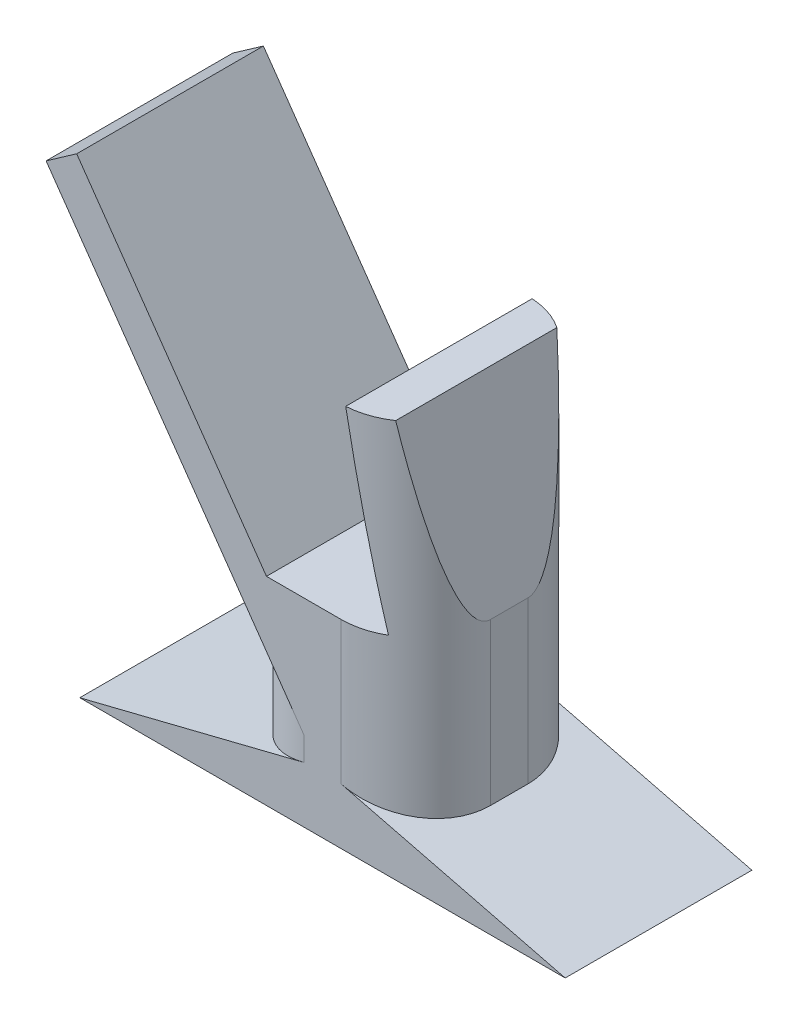
from build123d import *

# Parameters (mm, degrees)
BOSS_EXTRUDE1_DEPTH     = 12.7
FILLET2_R               = 5.08
SKETCH5_R               = 1.27
CUT_EXTRUDE1_DEPTH      = 1
CUT_EXTRUDE1_DEPTH_BACK = 32.936884148


with BuildPart() as part:
    # Sketch2 → Boss-Extrude1 (new body)
    with BuildSketch(Plane.XY):
        Polygon((-10.16, 13.500858924), (-2.54, 13.500858924), (-4.779352655, 26.200858924), (-2.239352655, 26.200858924), (0, 13.500858924), (0, 2.54), (10.16, 0), (0, 0), (-12.7, 0), (-22.86, 0), (-12.7, 2.54), (-12.7, 12.7), (-25.149690029, 30.48), (-23.069043837, 31.936884148), align=None)
    extrude(amount=BOSS_EXTRUDE1_DEPTH)

    # Fillet2
    fillet2_edges = [part.edges().sort_by_distance(p)[0] for p in [
        (-12.7, 7.62, 12.7),
        (-12.7, 7.62, 0),
        (0, 8.020429462, 0),
        (0, 8.020429462, 12.7),
    ]]
    fillet(fillet2_edges, radius=FILLET2_R)

    # Sketch5 → Cut-Extrude1 (cut, two sides)
    with BuildSketch(Plane.XZ) as cut_extrude1_sk:
        with Locations((-6.35, 6.35)):
            Circle(SKETCH5_R)
    extrude(amount=CUT_EXTRUDE1_DEPTH, mode=Mode.SUBTRACT)
    extrude(cut_extrude1_sk.sketch, amount=-CUT_EXTRUDE1_DEPTH_BACK, mode=Mode.SUBTRACT)


solid = part.part
